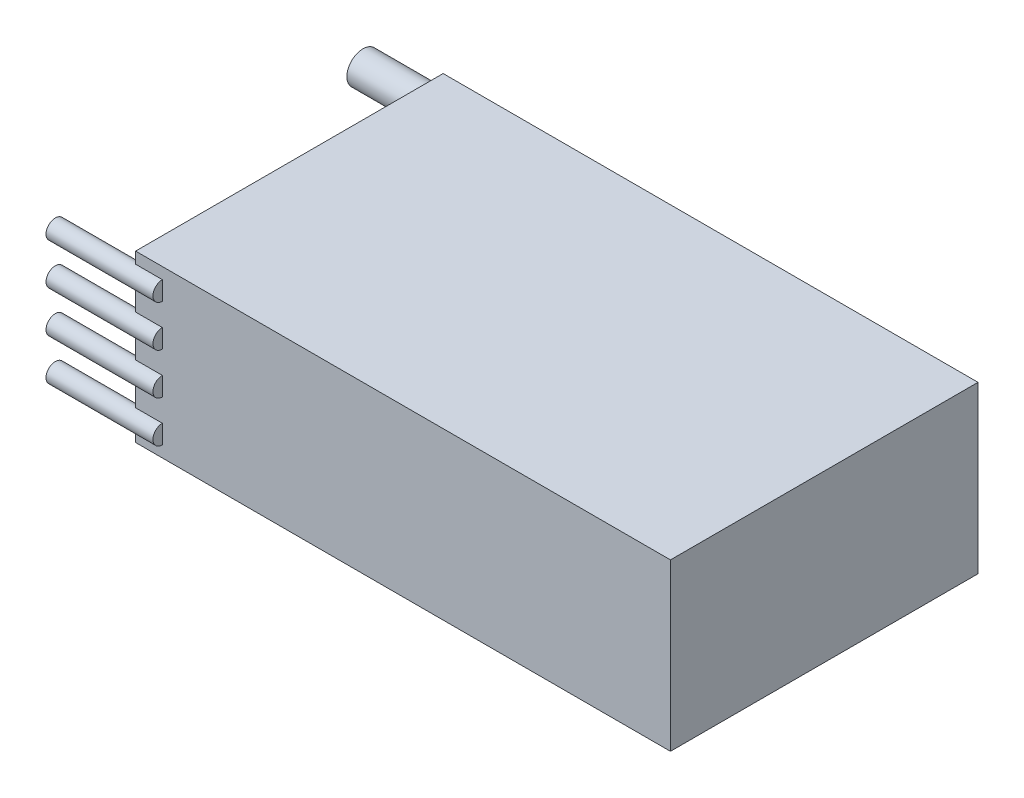
from build123d import *

# Parameters (mm, degrees)
SKETCH1_W                = 50.8
SKETCH1_H                = 29.21
BOSS_EXTRUDE1_DEPTH      = 15.748
SKETCH2_R                = 1.524
SKETCH2_R_2              = 0.889
BOSS_EXTRUDE2_DEPTH      = 7.62
BOSS_EXTRUDE2_DEPTH_BACK = 2.54


with BuildPart() as part:
    # Sketch1 → Boss-Extrude1 (new body)
    with BuildSketch(Plane(origin=(0, 0, 0), x_dir=(1, 0, 0), z_dir=(0, 1, 0))):
        Rectangle(SKETCH1_W, SKETCH1_H)
    extrude(amount=BOSS_EXTRUDE1_DEPTH)

    # Sketch2 → Boss-Extrude2 (add, two sides)
    with BuildSketch(Plane.ZY.offset(25.4)) as boss_extrude2_sk:
        with Locations((-14.605, 12.446)):
            Circle(SKETCH2_R)
        with Locations((14.605, 9.8425)):
            Circle(SKETCH2_R_2)
        with Locations((14.605, 13.7795)):
            Circle(SKETCH2_R_2)
        with Locations((14.605, 5.9055)):
            Circle(SKETCH2_R_2)
        with Locations((14.605, 1.9685)):
            Circle(SKETCH2_R_2)
        with Locations((-14.605, 3.302)):
            Circle(SKETCH2_R)
    extrude(amount=BOSS_EXTRUDE2_DEPTH)
    extrude(boss_extrude2_sk.sketch, amount=-BOSS_EXTRUDE2_DEPTH_BACK)


solid = part.part
